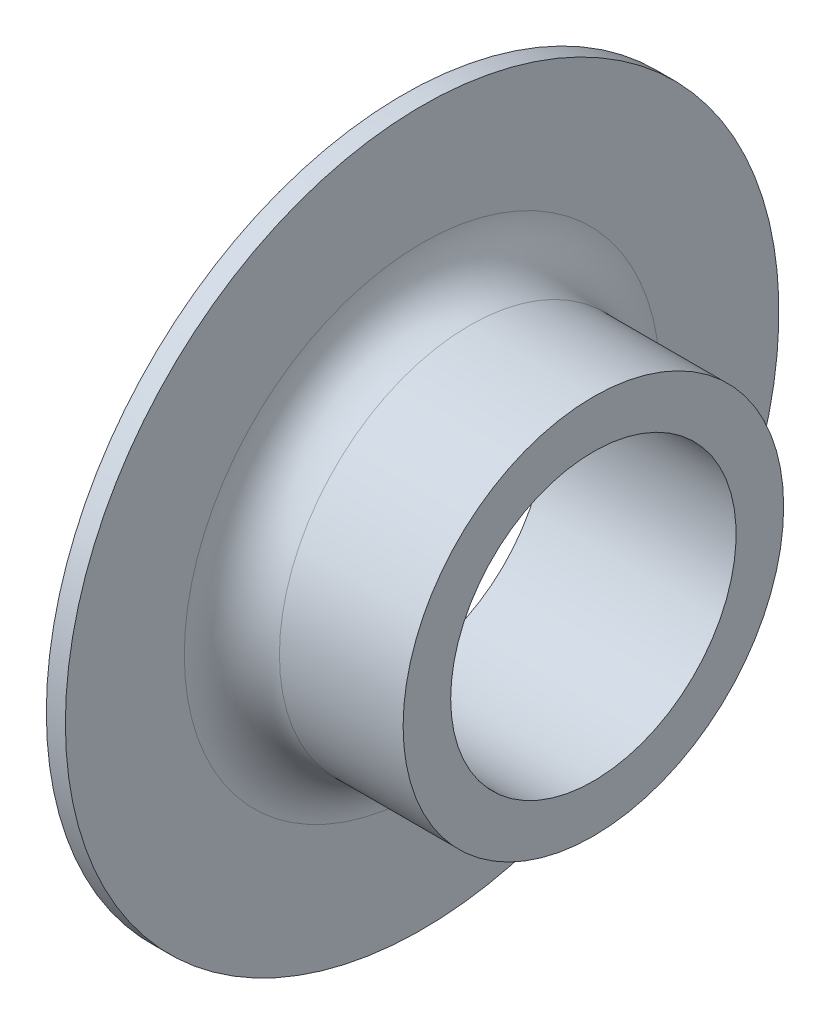
from build123d import *

# Parameters (mm, degrees)
RADYUS1_R = 5


with BuildPart() as part:
    # Çizim1 → Döndür1 (revolve)
    with BuildSketch(Plane.XY):
        Polygon((0, 37.5), (2, 37.5), (2, 20), (20, 20), (20, 15), (0, 15), align=None)
    revolve(axis=Axis((0, 0, 0), (1, 0, 0)))

    # Radyus1
    radyus1_edges = [part.edges().sort_by_distance(p)[0] for p in [
        (2, -20, 0),
    ]]
    fillet(radyus1_edges, radius=RADYUS1_R)


solid = part.part
